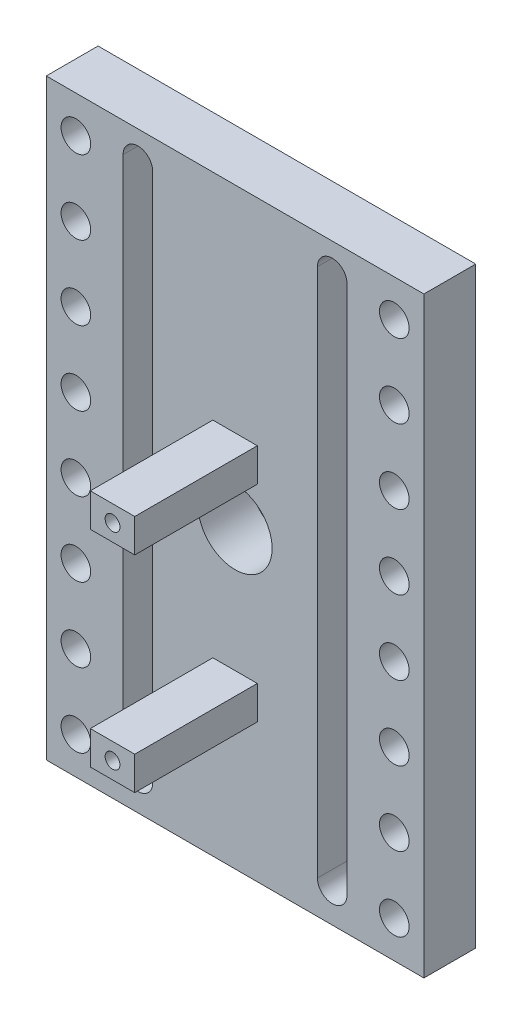
from build123d import *

# Parameters (mm, degrees)
SKETCH1_W           = 35
SKETCH1_H           = 80
BOSS_EXTRUDE1_DEPTH = 7
SKETCH2_W           = 6
SKETCH2_H           = 4.5
SKETCH2_R           = 1
BOSS_EXTRUDE2_DEPTH = 16.55
SKETCH3_R           = 5
CUT_EXTRUDE1_DEPTH  = 7
CUT_EXTRUDE2_DEPTH  = 15
SKETCH5_W           = 8
SKETCH5_H           = 80
SKETCH5_R           = 2
BOSS_EXTRUDE3_DEPTH = 7


with BuildPart() as part:
    # Sketch1 → Boss-Extrude1 (new body)
    with BuildSketch(Plane.XY):
        Rectangle(SKETCH1_W, SKETCH1_H)
    extrude(amount=BOSS_EXTRUDE1_DEPTH)

    # Sketch2 → Boss-Extrude2 (add)
    with BuildSketch(Plane.XY.offset(7)):
        with Locations((0, 8.75)):
            Rectangle(SKETCH2_W, SKETCH2_H)
        with Locations((0, 8.75)):
            Circle(SKETCH2_R, mode=Mode.SUBTRACT)
        with Locations((0, -19.05)):
            Rectangle(SKETCH2_W, SKETCH2_H)
        with Locations((0, -19.05)):
            Circle(SKETCH2_R, mode=Mode.SUBTRACT)
    extrude(amount=BOSS_EXTRUDE2_DEPTH)

    # Sketch3 → Cut-Extrude1 (cut)
    with BuildSketch(Plane.XY.offset(7)):
        Circle(SKETCH3_R)
    extrude(amount=-CUT_EXTRUDE1_DEPTH, mode=Mode.SUBTRACT)

    # Sketch4 → Cut-Extrude2 (cut)
    with BuildSketch(Plane.XY.offset(7)):
        with BuildLine():
            Line((-11.12, 36), (-11.12, -35.5))
            ThreePointArc((-11.12, -35.5), (-13.12, -37.5), (-15.12, -35.5))
            Line((-15.12, -35.5), (-15.12, 36))
            ThreePointArc((-15.12, 36), (-13.12, 38), (-11.12, 36))
        make_face()
        with BuildLine():
            Line((11.12, 36), (11.12, -35.5))
            ThreePointArc((11.12, -35.5), (13.12, -37.5), (15.12, -35.5))
            Line((15.12, -35.5), (15.12, 36))
            ThreePointArc((15.12, 36), (13.12, 38), (11.12, 36))
        make_face()
    extrude(amount=-CUT_EXTRUDE2_DEPTH, mode=Mode.SUBTRACT)

    # Sketch5 → Boss-Extrude3 (add)
    with BuildSketch(Plane.XY.offset(7)):
        with Locations((21.5, 0)):
            Rectangle(SKETCH5_W, SKETCH5_H)
        with Locations((21.5, 35)):
            Circle(SKETCH5_R, mode=Mode.SUBTRACT)
        with Locations((21.5, 25)):
            Circle(SKETCH5_R, mode=Mode.SUBTRACT)
        with Locations((21.5, 15)):
            Circle(SKETCH5_R, mode=Mode.SUBTRACT)
        with Locations((21.5, 5)):
            Circle(SKETCH5_R, mode=Mode.SUBTRACT)
        with Locations((21.5, -5)):
            Circle(SKETCH5_R, mode=Mode.SUBTRACT)
        with Locations((21.5, -15)):
            Circle(SKETCH5_R, mode=Mode.SUBTRACT)
        with Locations((21.5, -25)):
            Circle(SKETCH5_R, mode=Mode.SUBTRACT)
        with Locations((21.5, -35)):
            Circle(SKETCH5_R, mode=Mode.SUBTRACT)
    boss_extrude3 = extrude(amount=-BOSS_EXTRUDE3_DEPTH)

    # Mirror1: Boss-Extrude3 across plane
    add(boss_extrude3.mirror(Plane(origin=(0, 0, 0), x_dir=(0, 0, 1), z_dir=(1, 0, 0))))


solid = part.part
